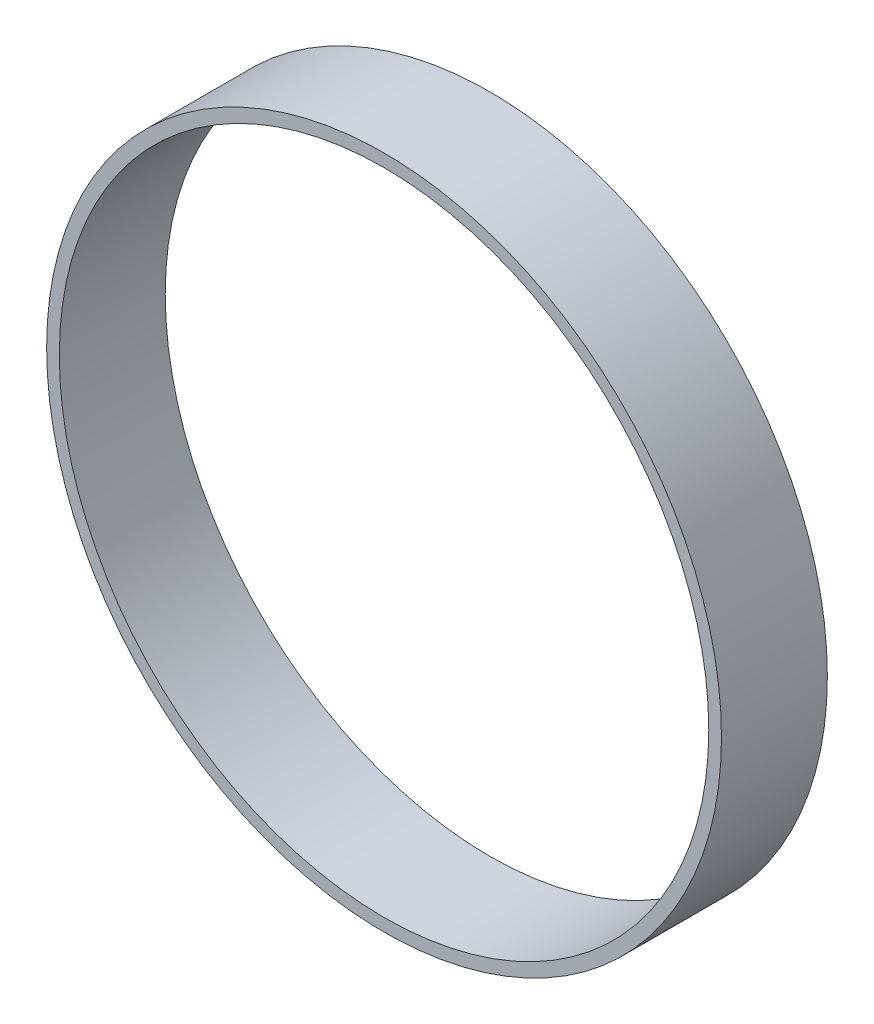
from build123d import *

# Parameters (mm, degrees)
CROQUIS1_R              = 47.8
CROQUIS1_R_2            = 46
SALIENTE_EXTRUIR1_DEPTH = 15


with BuildPart() as part:
    # Croquis1 → Saliente-Extruir1 (new body)
    with BuildSketch(Plane.XY):
        with Locations((-117.461114308, 21.076825127)):
            Circle(CROQUIS1_R)
        with Locations((-117.461114308, 21.076825127)):
            Circle(CROQUIS1_R_2, mode=Mode.SUBTRACT)
    extrude(amount=SALIENTE_EXTRUIR1_DEPTH)


solid = part.part
